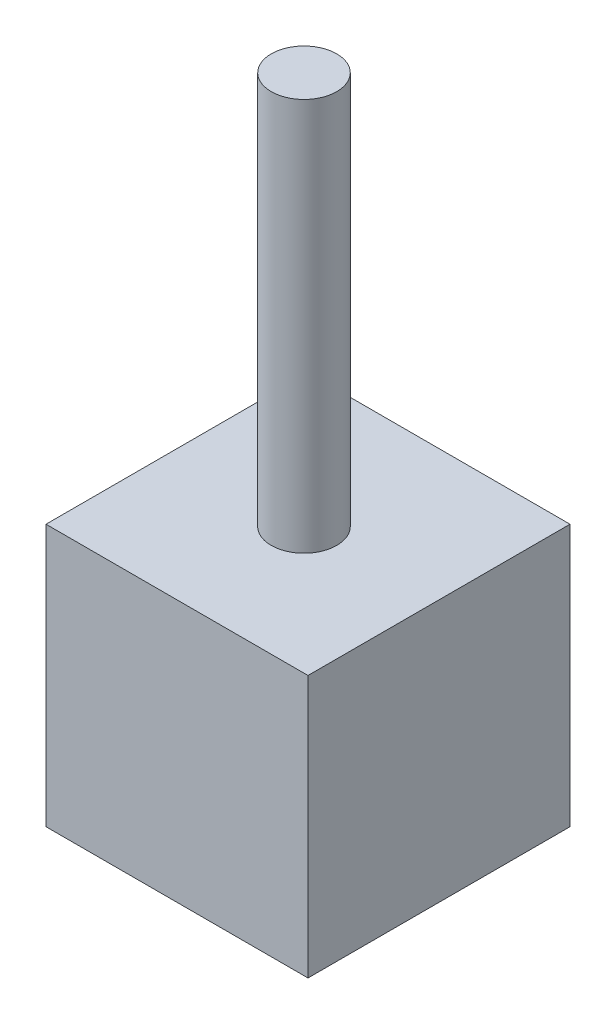
from build123d import *

# Parameters (mm, degrees)
SKETCH1_W           = 50.8
SKETCH1_H           = 50.8
BOSS_EXTRUDE1_DEPTH = 50.8
SKETCH2_R           = 6.35
BOSS_EXTRUDE2_DEPTH = 76.2


with BuildPart() as part:
    # Sketch1 → Boss-Extrude1 (new body)
    with BuildSketch(Plane(origin=(0, 0, 0), x_dir=(1, 0, 0), z_dir=(0, 1, 0))):
        with Locations((0, 0.779824561)):
            Rectangle(SKETCH1_W, SKETCH1_H)
    extrude(amount=BOSS_EXTRUDE1_DEPTH)

    # Sketch2 → Boss-Extrude2 (add)
    with BuildSketch(Plane(origin=(0, 50.8, 0), x_dir=(1, 0, 0), z_dir=(0, 1, 0))):
        Circle(SKETCH2_R)
    extrude(amount=BOSS_EXTRUDE2_DEPTH)


solid = part.part
